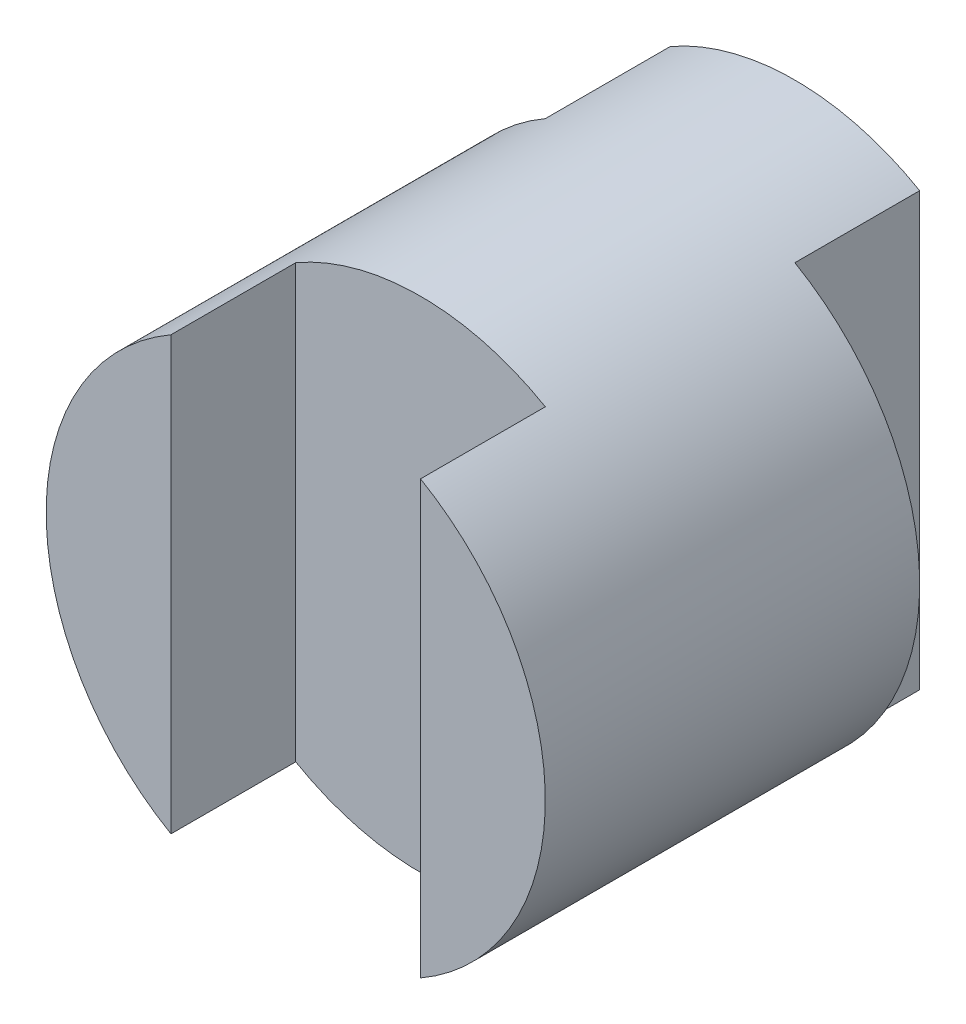
from build123d import *

# Parameters (mm, degrees)
SKETCH1_R           = 2
BOSS_EXTRUDE1_DEPTH = 4
SKETCH2_W           = 2
SKETCH2_H           = 1
CUT_EXTRUDE1_DEPTH  = 5
SKETCH3_W           = 1
SKETCH3_H           = 1
CUT_EXTRUDE2_DEPTH  = 5


with BuildPart() as part:
    # Sketch1 → Boss-Extrude1 (new body)
    with BuildSketch(Plane.XY):
        Circle(SKETCH1_R)
    extrude(amount=BOSS_EXTRUDE1_DEPTH)

    # Sketch2 → Cut-Extrude1 (cut, symmetric)
    with BuildSketch(Plane(origin=(0, 0, 0), x_dir=(1, 0, 0), z_dir=(0, 1, 0))):
        Polygon((-2.31386892, -1), (-1, -1), (-1, 0.234035397), (-2.586760402, 0.199881392), align=None)
        with Locations((0, -3.5)):
            Rectangle(SKETCH2_W, SKETCH2_H)
    extrude(amount=CUT_EXTRUDE1_DEPTH, both=True, mode=Mode.SUBTRACT)

    # Sketch3 → Cut-Extrude2 (cut, symmetric)
    with BuildSketch(Plane(origin=(0, 0, 0), x_dir=(1, 0, 0), z_dir=(0, 1, 0))):
        with Locations((1.5, -0.5)):
            Rectangle(SKETCH3_W, SKETCH3_H)
    extrude(amount=CUT_EXTRUDE2_DEPTH, both=True, mode=Mode.SUBTRACT)


solid = part.part
